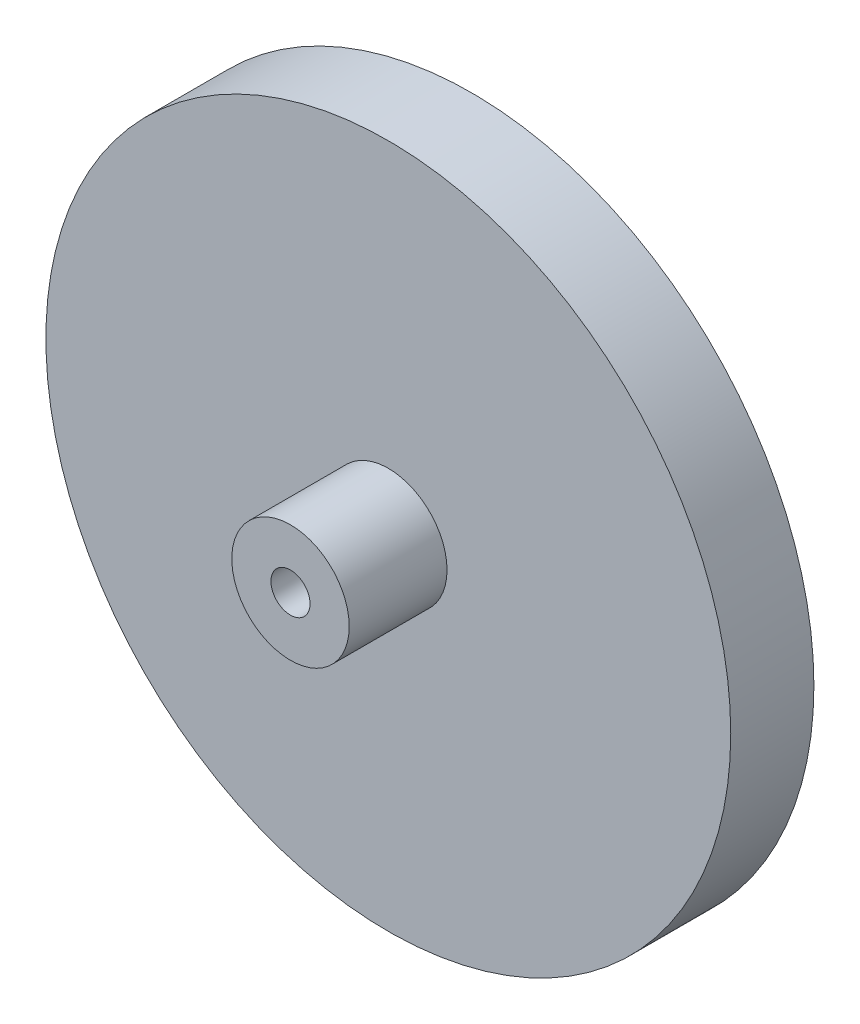
from build123d import *

# Parameters (mm, degrees)
SKETCH1_R           = 35
SKETCH1_R_2         = 2
BOSS_EXTRUDE1_DEPTH = 8.5
SKETCH2_R           = 6
SKETCH2_R_2         = 2
BOSS_EXTRUDE2_DEPTH = 10


with BuildPart() as part:
    # Sketch1 → Boss-Extrude1 (new body)
    with BuildSketch(Plane.XY):
        Circle(SKETCH1_R)
        Circle(SKETCH1_R_2, mode=Mode.SUBTRACT)
    extrude(amount=BOSS_EXTRUDE1_DEPTH)

    # Sketch2 → Boss-Extrude2 (add)
    with BuildSketch(Plane.XY.offset(8.5)):
        Circle(SKETCH2_R)
        Circle(SKETCH2_R_2, mode=Mode.SUBTRACT)
    extrude(amount=BOSS_EXTRUDE2_DEPTH)


solid = part.part
